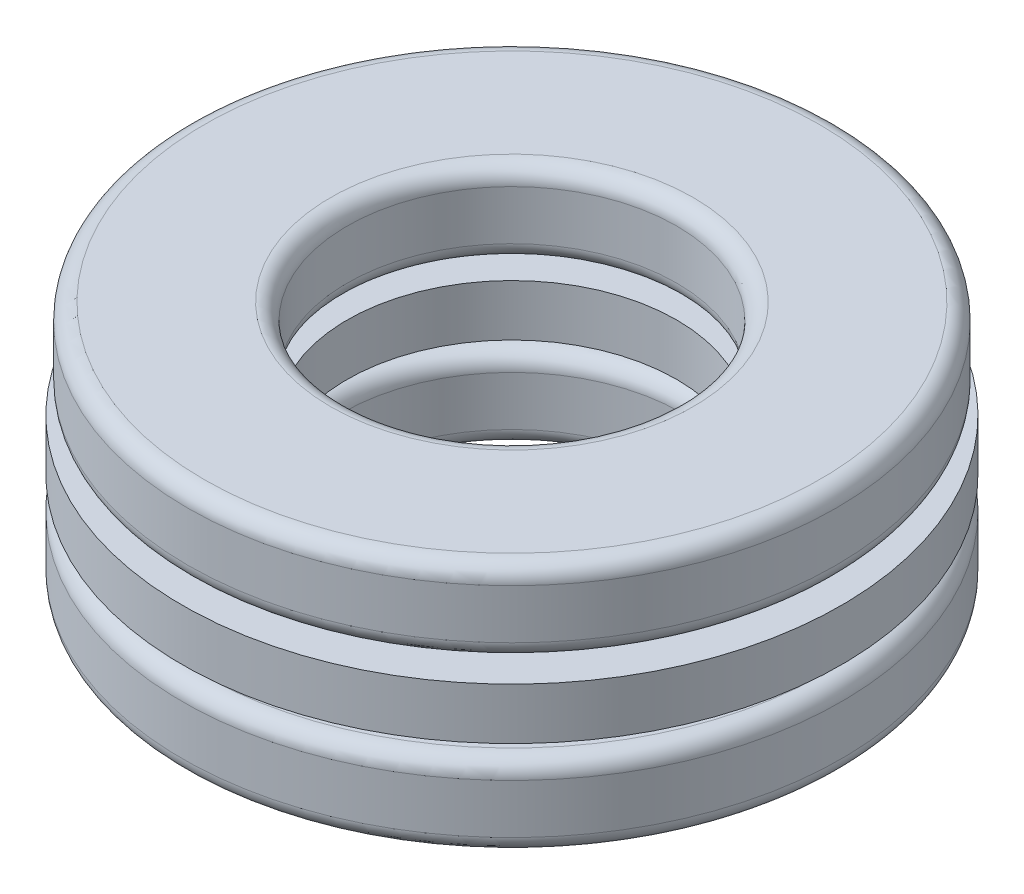
from build123d import *

# Parameters (mm, degrees)
SKETCH1_W         = 3
SKETCH1_H         = 0.9375
CIRPATTERN1_COUNT = 5
CIRPATTERN1_ANGLE = 288
CIRPATTERN2_COUNT = 5


with BuildPart() as part:
    # Sketch1 → Revolve1 (revolve)
    with BuildSketch(Plane(origin=(0, 0, 0), x_dir=(0, 0, -1), z_dir=(1, 0, 0))):
        with Locations((-4.5, 0)):
            Rectangle(SKETCH1_W, SKETCH1_H)
    revolve(axis=Axis((0, -2.25, 0), (0, 1, 0)))

    # Sketch3 → Cut-Revolve1 (revolve, cut)
    with BuildSketch(Plane(origin=(0, 0, 0), x_dir=(0, 0, -1), z_dir=(1, 0, 0))):
        with BuildLine():
            Line((-4.5, 0.75), (-4.5, -0.75))
            ThreePointArc((-4.5, -0.75), (-5.25, 0), (-4.5, 0.75))
        make_face()
    cut_revolve1 = revolve(axis=Axis((0, 0.75, 4.5), (0, -1, 0)), mode=Mode.SUBTRACT)

    # CirPattern2: Cut-Revolve1 ×5 about axis
    cirpattern2_axis = Axis((0, 0, 0), (0, 1, 0))
    for i in range(1, CIRPATTERN2_COUNT):
        add(cut_revolve1.rotate(cirpattern2_axis, i * 360 / CIRPATTERN2_COUNT), mode=Mode.SUBTRACT)


with BuildPart() as body_2:
    # Sketch2 → Revolve2 (revolve)
    with BuildSketch(Plane(origin=(0, 0, 0), x_dir=(0, 0, -1), z_dir=(1, 0, 0))):
        with BuildLine():
            Line((-4.5, 0.75), (-4.5, -0.75))
            ThreePointArc((-4.5, -0.75), (-5.25, 0), (-4.5, 0.75))
        make_face()
    revolve(axis=Axis((0, 0.75, 4.5), (0, -1, 0)))


with BuildPart() as cirpattern1_1:
    # CirPattern1: pattern copy
    add(body_2.part.rotate(Axis((0, 2.25, 0), (0, -1, 0)), 1 * CIRPATTERN1_ANGLE / (CIRPATTERN1_COUNT - 1)))


with BuildPart() as cirpattern1_2:
    # CirPattern1: pattern copy
    add(body_2.part.rotate(Axis((0, 2.25, 0), (0, -1, 0)), 2 * CIRPATTERN1_ANGLE / (CIRPATTERN1_COUNT - 1)))


with BuildPart() as cirpattern1_3:
    # CirPattern1: pattern copy
    add(body_2.part.rotate(Axis((0, 2.25, 0), (0, -1, 0)), 3 * CIRPATTERN1_ANGLE / (CIRPATTERN1_COUNT - 1)))


with BuildPart() as cirpattern1_4:
    # CirPattern1: pattern copy
    add(body_2.part.rotate(Axis((0, 2.25, 0), (0, -1, 0)), 4 * CIRPATTERN1_ANGLE / (CIRPATTERN1_COUNT - 1)))


with BuildPart() as body_7:
    # Sketch4 → Revolve3 (revolve)
    with BuildSketch(Plane(origin=(0, 0, 0), x_dir=(0, 0, -1), z_dir=(1, 0, 0))):
        with BuildLine():
            Line((-5.6, 2.25), (-3.3, 2.25))
            ThreePointArc((-3.3, 2.25), (-3.087867966, 2.162132034), (-3, 1.95))
            Line((-3, 1.95), (-3, 1.05))
            ThreePointArc((-3, 1.05), (-3.087867966, 0.837867966), (-3.3, 0.75))
            Line((-3.3, 0.75), (-5.6, 0.75))
            ThreePointArc((-5.6, 0.75), (-5.812132034, 0.837867966), (-5.9, 1.05))
            Line((-5.9, 1.05), (-5.9, 1.95))
            ThreePointArc((-5.9, 1.95), (-5.812132034, 2.162132034), (-5.6, 2.25))
        make_face()
        with BuildLine():
            Line((-5.7, -2.25), (-3.4, -2.25))
            ThreePointArc((-3.4, -2.25), (-3.187867966, -2.162132034), (-3.1, -1.95))
            Line((-3.1, -1.95), (-3.1, -1.05))
            ThreePointArc((-3.1, -1.05), (-3.187867966, -0.837867966), (-3.4, -0.75))
            Line((-3.4, -0.75), (-5.7, -0.75))
            ThreePointArc((-5.7, -0.75), (-5.912132034, -0.837867966), (-6, -1.05))
            Line((-6, -1.05), (-6, -1.95))
            ThreePointArc((-6, -1.95), (-5.912132034, -2.162132034), (-5.7, -2.25))
        make_face()
    revolve(axis=Axis((0, -2.25, 0), (0, 1, 0)))


solid = Compound([part.part, body_2.part, cirpattern1_1.part, cirpattern1_2.part, cirpattern1_3.part, cirpattern1_4.part, body_7.part])
